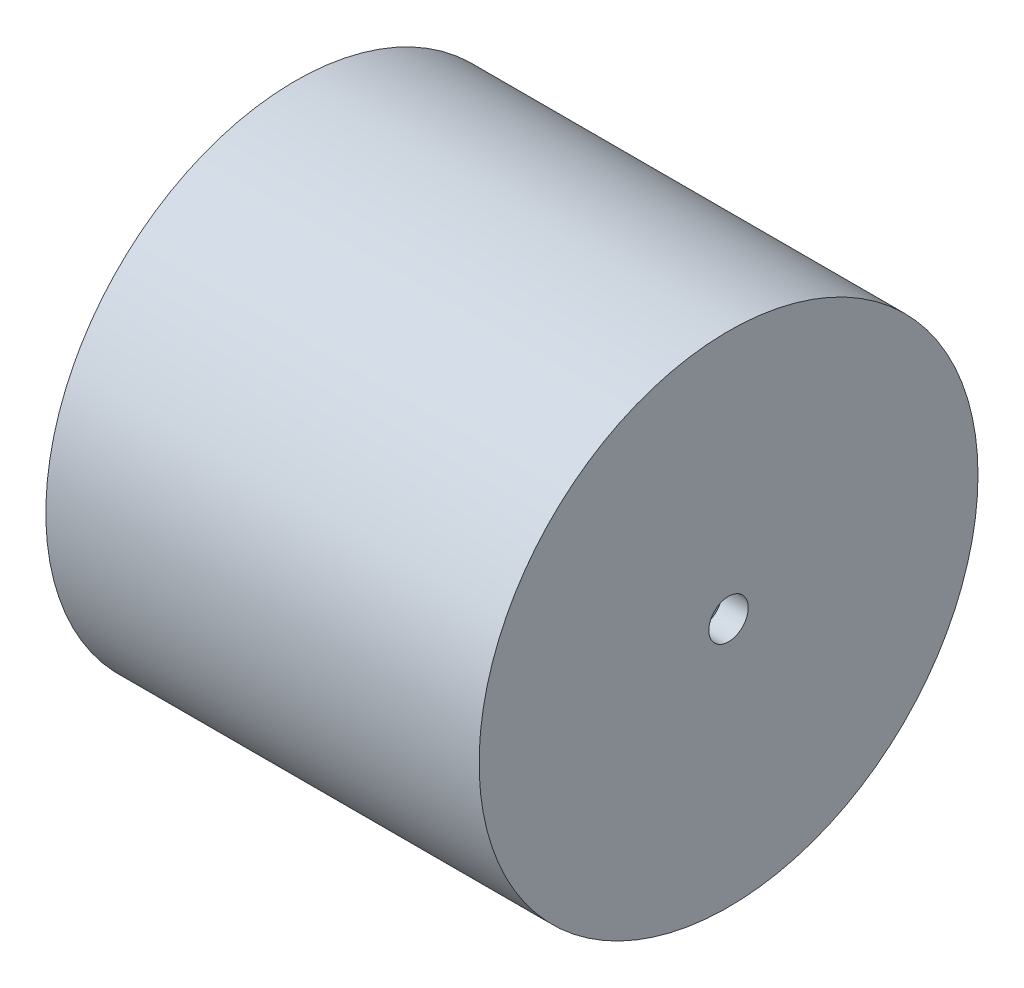
from build123d import *

# Parameters (mm, degrees)
SKETCH1_R           = 19
BOSS_EXTRUDE1_DEPTH = 33
SKETCH2_R           = 1.5
CUT_EXTRUDE1_DEPTH  = 2


with BuildPart() as part:
    # Sketch1 → Boss-Extrude1 (new body)
    with BuildSketch(Plane(origin=(0, 0, 0), x_dir=(0, 0, -1), z_dir=(1, 0, 0))):
        Circle(SKETCH1_R)
    extrude(amount=BOSS_EXTRUDE1_DEPTH)

    # Sketch2 → Cut-Extrude1 (cut)
    with BuildSketch(Plane(origin=(33, 0, 0), x_dir=(0, 0, -1), z_dir=(1, 0, 0))):
        Circle(SKETCH2_R)
    extrude(amount=-CUT_EXTRUDE1_DEPTH, mode=Mode.SUBTRACT)


solid = part.part
